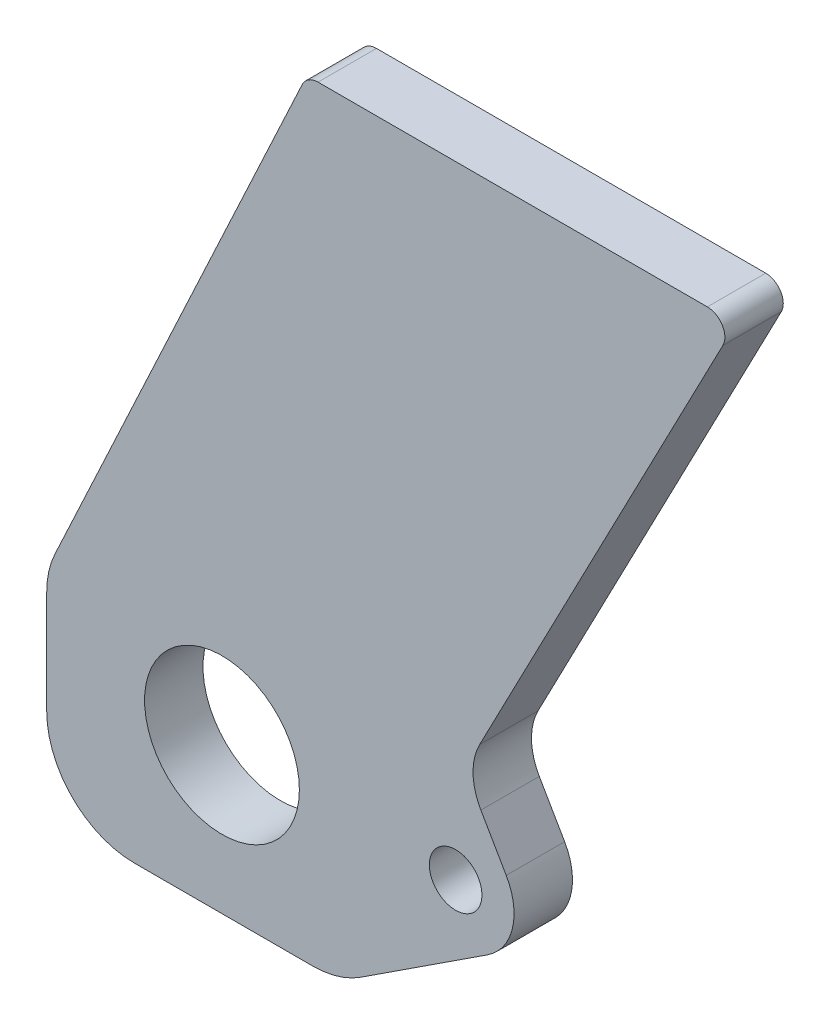
from build123d import *

# Parameters (mm, degrees)
SKETCH1_R          = 13.25
SKETCH1_R_2        = 4.5
BASE_EXTRUDE_DEPTH = 10


with BuildPart() as part:
    # Sketch1 → Base-Extrude (new body)
    with BuildSketch(Plane.XY):
        with BuildLine():
            Line((45.466783574, -8.373426859), (23.737112795, -22.560140288))
            ThreePointArc((23.737112795, -22.560140288), (19.814664383, -24.377101661), (15.536937435, -25))
            Line((15.536937435, -25), (-15, -25))
            ThreePointArc((-15, -25), (-25.606601718, -20.606601718), (-30, -10))
            Line((-30, -10), (-30, 7.67458006))
            ThreePointArc((-30, 7.67458006), (-29.644440107, 10.921174269), (-28.594616806, 14.013853986))
            Line((-28.594616806, 14.013853986), (13.724668775, 104.767854785))
            ThreePointArc((13.724668775, 104.767854785), (14.831693311, 106.030174337), (16.443592136, 106.5))
            Line((16.443592136, 106.5), (83.088534362, 106.5))
            ThreePointArc((83.088534362, 106.5), (85.653269974, 105.056319774), (85.749566861, 102.11475416))
            Line((85.749566861, 102.11475416), (44.112570075, 22.130827513))
            ThreePointArc((44.112570075, 22.130827513), (42.985058136, 17.295192531), (44.322424369, 12.513341381))
            Line((44.322424369, 12.513341381), (48.660254038, 5))
            ThreePointArc((48.660254038, 5), (49.726532496, -2.322620416), (45.466783574, -8.373426859))
        make_face()
        Circle(SKETCH1_R, mode=Mode.SUBTRACT)
        with Locations((40, 0)):
            Circle(SKETCH1_R_2, mode=Mode.SUBTRACT)
    extrude(amount=BASE_EXTRUDE_DEPTH)


solid = part.part
